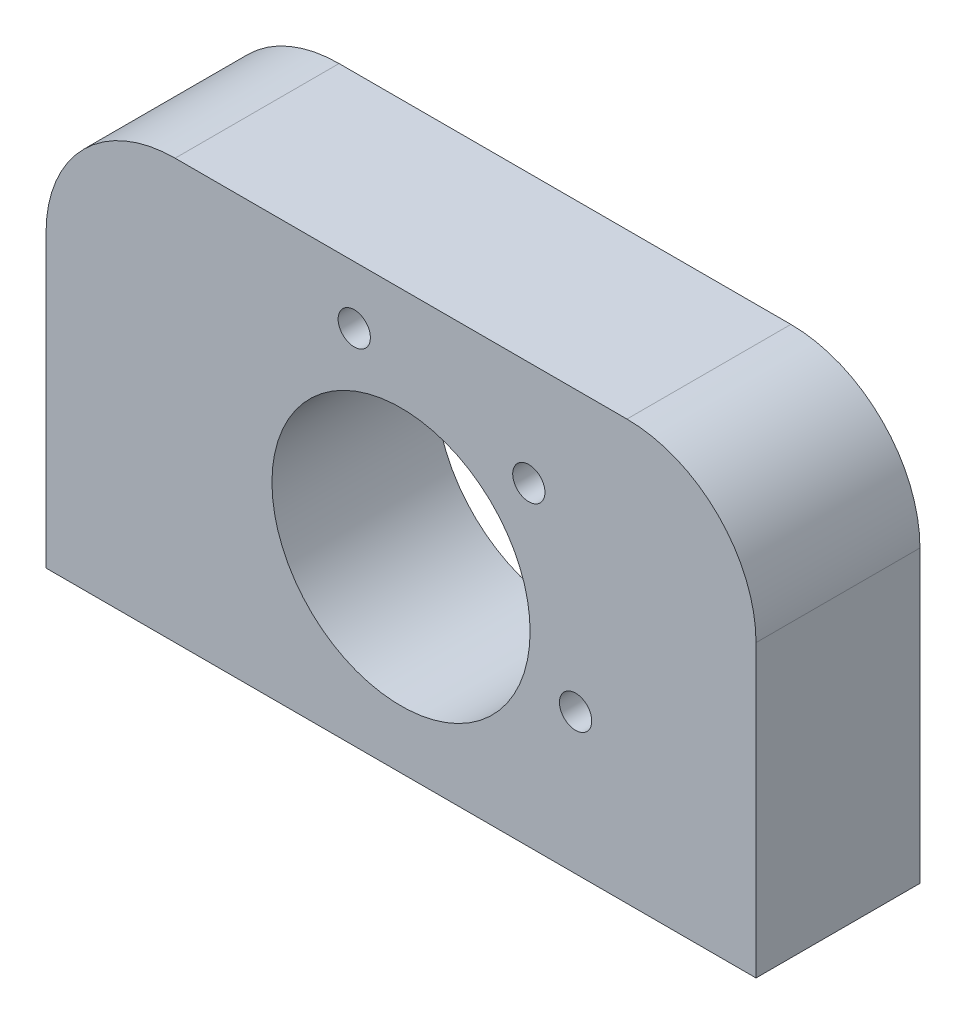
from build123d import *

# Parameters (mm, degrees)
SKETCH2_R                       = 10
BOSS_EXTRUDE1_DEPTH             = 12.7
TAP_DRILL_FOR_M3X0_5_TAP1_D     = 2.5
TAP_DRILL_FOR_M3X0_5_TAP1_DEPTH = 25
TAP_DRILL_FOR_M3X0_5_TAP1_TIP   = 0.751075774
M4X0_7_TAPPED_HOLE1_D           = 3.3
M4X0_7_TAPPED_HOLE1_DEPTH       = 14
M4X0_7_TAPPED_HOLE1_TIP         = 0.991420021


with BuildPart() as part:
    # Sketch2 → Boss-Extrude1 (new body)
    with BuildSketch(Plane.XY):
        with BuildLine():
            Line((27.5, 0), (-27.5, 0))
            Line((-27.5, 0), (-27.5, 22.5))
            ThreePointArc((-27.5, 22.5), (-24.571067812, 29.571067812), (-17.5, 32.5))
            Line((-17.5, 32.5), (17.5, 32.5))
            ThreePointArc((17.5, 32.5), (24.571067812, 29.571067812), (27.5, 22.5))
            Line((27.5, 22.5), (27.5, 0))
        make_face()
        with Locations((0, 14.5)):
            Circle(SKETCH2_R, mode=Mode.SUBTRACT)
    extrude(amount=BOSS_EXTRUDE1_DEPTH)

    # Tap Drill for M3x0.5 Tap1
    with Locations(Plane(origin=(13.522961568, 10.876533369, 0), x_dir=(-1, 0, 0), z_dir=(0, 0, -1))):
        with Locations((0, 0), (3.623466631, 13.522961568), (17.146428199, 17.146428199)):
            Hole(TAP_DRILL_FOR_M3X0_5_TAP1_D / 2, depth=TAP_DRILL_FOR_M3X0_5_TAP1_DEPTH)
            with Locations((0, 0, -(TAP_DRILL_FOR_M3X0_5_TAP1_DEPTH + TAP_DRILL_FOR_M3X0_5_TAP1_TIP / 2))):  # 118° drill point
                Cone(0, TAP_DRILL_FOR_M3X0_5_TAP1_D / 2, TAP_DRILL_FOR_M3X0_5_TAP1_TIP, mode=Mode.SUBTRACT)

    # M4x0.7 Tapped Hole1
    with Locations(Plane(origin=(22.25, 0, 6.35), x_dir=(0, 0, -1), z_dir=(0, -1, 0))):
        with Locations((0, 0), (0, -44.5)):
            Hole(M4X0_7_TAPPED_HOLE1_D / 2, depth=M4X0_7_TAPPED_HOLE1_DEPTH)
            with Locations((0, 0, -(M4X0_7_TAPPED_HOLE1_DEPTH + M4X0_7_TAPPED_HOLE1_TIP / 2))):  # 118° drill point
                Cone(0, M4X0_7_TAPPED_HOLE1_D / 2, M4X0_7_TAPPED_HOLE1_TIP, mode=Mode.SUBTRACT)


solid = part.part
